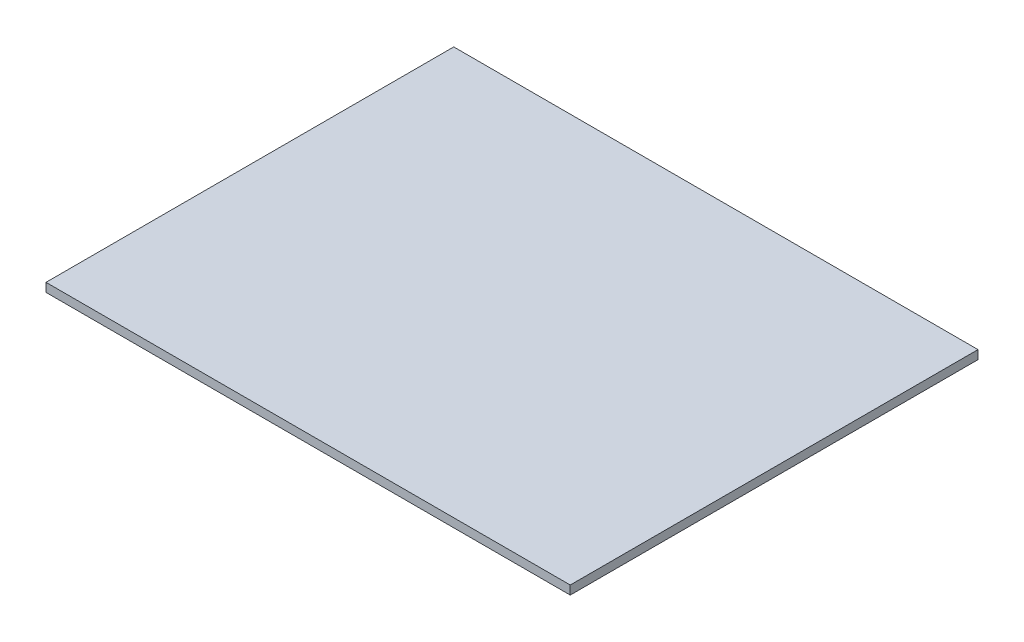
from build123d import *

# Parameters (mm, degrees)
SKETCH1_W           = 90
SKETCH1_H           = 70
BOSS_EXTRUDE1_DEPTH = 1.5


with BuildPart() as part:
    # Sketch1 → Boss-Extrude1 (new body)
    with BuildSketch(Plane(origin=(0, 0, 0), x_dir=(1, 0, 0), z_dir=(0, 1, 0))):
        with Locations((45, 35)):
            Rectangle(SKETCH1_W, SKETCH1_H)
    extrude(amount=BOSS_EXTRUDE1_DEPTH)


solid = part.part
